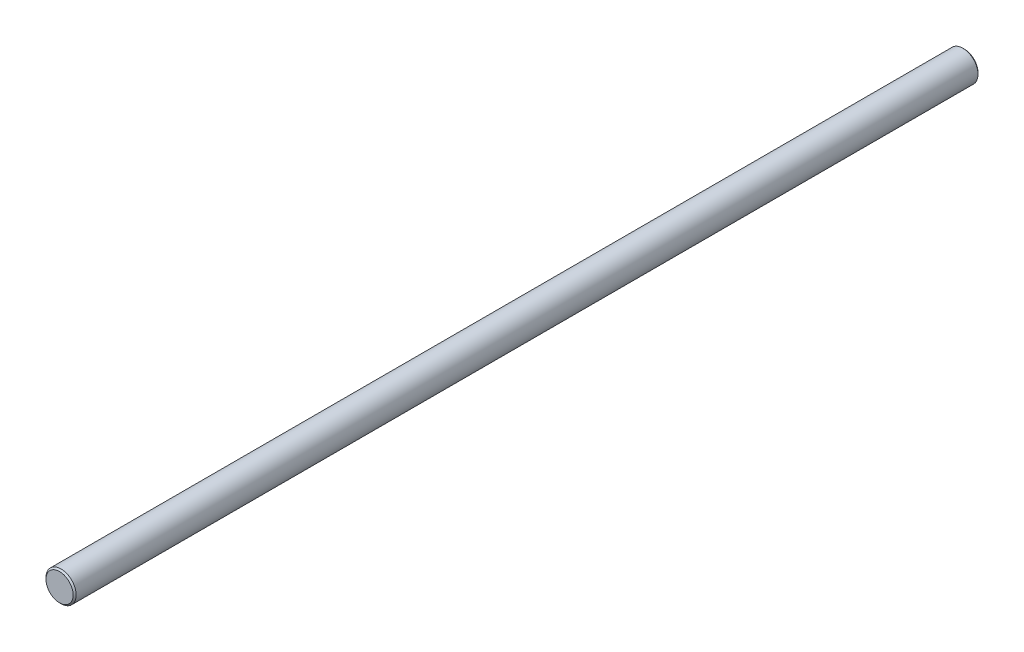
from build123d import *

# Parameters (mm, degrees)
ESBO_O1_R                = 5
RESSALTO_EXTRUS_O1_DEPTH = 300
CHANFRO1_SIZE            = 0.5


with BuildPart() as part:
    # Esboço1 → Ressalto-extrusão1 (new body)
    with BuildSketch(Plane.XY):
        Circle(ESBO_O1_R)
    extrude(amount=RESSALTO_EXTRUS_O1_DEPTH)

    # Chanfro1
    chanfro1_edges = [part.edges().sort_by_distance(p)[0] for p in [
        (-5, 0, 0),
        (-5, 0, 300),
    ]]
    chamfer(chanfro1_edges, length=CHANFRO1_SIZE)


solid = part.part
